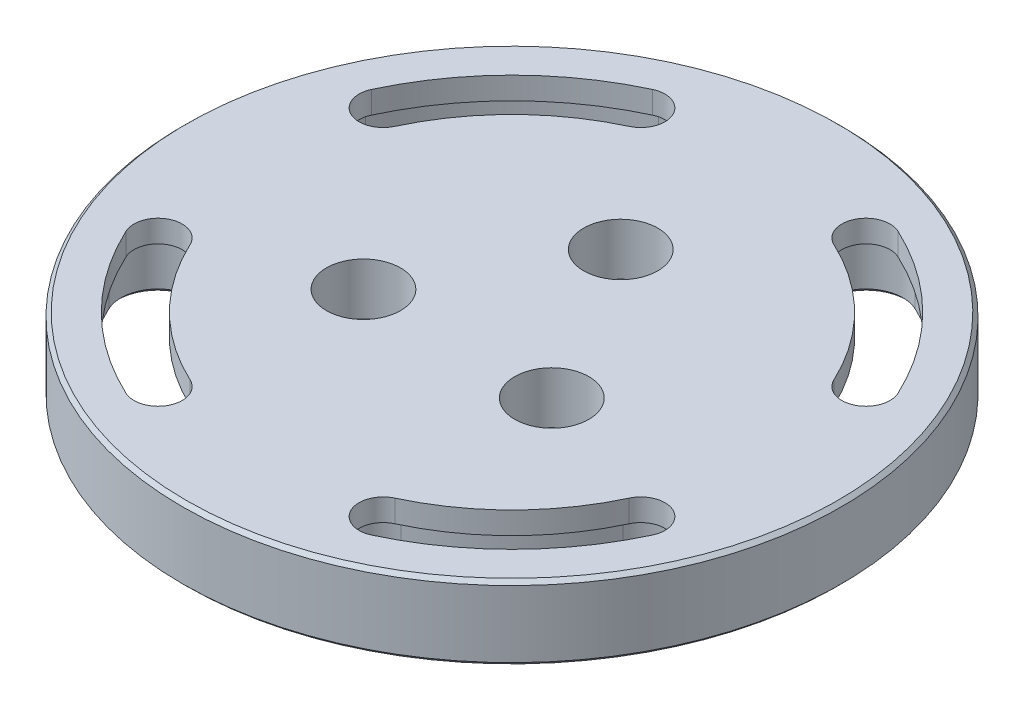
from build123d import *

# Parameters (mm, degrees)
SKETCH1_R           = 44.45
BOSS_EXTRUDE1_DEPTH = 10
BOSS_EXTRUDE2_DEPTH = 3
SKETCH3_R           = 5
CUT_EXTRUDE1_DEPTH  = 10
SKETCH4_R           = 5
SKETCH4_R_2         = 3.25
BOSS_EXTRUDE4_DEPTH = 3
CHAMFER1_SIZE       = 0.5


with BuildPart() as part:
    # Sketch1 → Boss-Extrude1 (new body)
    with BuildSketch(Plane(origin=(0, 0, 0), x_dir=(1, 0, 0), z_dir=(0, 1, 0))):
        with Locations(Location((0, 0, 0), (0, 0, 270))):
            Circle(SKETCH1_R)
        with BuildLine():
            ThreePointArc((37.087043144, 17.293972236), (28.935533906, 28.935533906), (17.293972236, 37.087043144))
            ThreePointArc((17.293972236, 37.087043144), (10.649341992, 34.668595517), (13.067789619, 28.023965273))
            ThreePointArc((13.067789619, 28.023965273), (21.864466094, 21.864466094), (28.023965273, 13.067789619))
            ThreePointArc((28.023965273, 13.067789619), (34.668595517, 10.649341992), (37.087043144, 17.293972236))
        make_face(mode=Mode.SUBTRACT)
        with BuildLine():
            ThreePointArc((17.293972236, -37.087043144), (28.935533906, -28.935533906), (37.087043144, -17.293972236))
            ThreePointArc((37.087043144, -17.293972236), (34.668595517, -10.649341992), (28.023965273, -13.067789619))
            ThreePointArc((28.023965273, -13.067789619), (21.864466094, -21.864466094), (13.067789619, -28.023965273))
            ThreePointArc((13.067789619, -28.023965273), (10.649341992, -34.668595517), (17.293972236, -37.087043144))
        make_face(mode=Mode.SUBTRACT)
        with BuildLine():
            ThreePointArc((-37.087043144, -17.293972236), (-28.935533906, -28.935533906), (-17.293972236, -37.087043144))
            ThreePointArc((-17.293972236, -37.087043144), (-10.649341992, -34.668595517), (-13.067789619, -28.023965273))
            ThreePointArc((-13.067789619, -28.023965273), (-21.864466094, -21.864466094), (-28.023965273, -13.067789619))
            ThreePointArc((-28.023965273, -13.067789619), (-34.668595517, -10.649341992), (-37.087043144, -17.293972236))
        make_face(mode=Mode.SUBTRACT)
        with BuildLine():
            ThreePointArc((-17.293972236, 37.087043144), (-28.935533906, 28.935533906), (-37.087043144, 17.293972236))
            ThreePointArc((-37.087043144, 17.293972236), (-34.668595517, 10.649341992), (-28.023965273, 13.067789619))
            ThreePointArc((-28.023965273, 13.067789619), (-21.864466094, 21.864466094), (-13.067789619, 28.023965273))
            ThreePointArc((-13.067789619, 28.023965273), (-10.649341992, 34.668595517), (-17.293972236, 37.087043144))
        make_face(mode=Mode.SUBTRACT)
    extrude(amount=BOSS_EXTRUDE1_DEPTH)

    # Sketch2 → Boss-Extrude2 (add)
    with BuildSketch(Plane(origin=(0, 10, 0), x_dir=(1, 0, 0), z_dir=(0, 1, 0))):
        with BuildLine():
            ThreePointArc((-17.293972236, 37.087043144), (-28.935533906, 28.935533906), (-37.087043144, 17.293972236))
            ThreePointArc((-37.087043144, 17.293972236), (-34.668595517, 10.649341992), (-28.023965273, 13.067789619))
            ThreePointArc((-28.023965273, 13.067789619), (-21.864466094, 21.864466094), (-13.067789619, 28.023965273))
            ThreePointArc((-13.067789619, 28.023965273), (-10.649341992, 34.668595517), (-17.293972236, 37.087043144))
        make_face()
        with BuildLine():
            ThreePointArc((-16.554390278, 35.501004516), (-12.23538062, 33.929013559), (-13.807371577, 29.610003901))
            ThreePointArc((-13.807371577, 29.610003901), (-23.101902961, 23.101902961), (-29.610003901, 13.807371577))
            ThreePointArc((-29.610003901, 13.807371577), (-33.929013559, 12.23538062), (-35.501004516, 16.554390278))
            ThreePointArc((-35.501004516, 16.554390278), (-27.698097039, 27.698097039), (-16.554390278, 35.501004516))
        make_face(mode=Mode.SUBTRACT)
        with BuildLine():
            ThreePointArc((17.293972236, 37.087043144), (10.649341992, 34.668595517), (13.067789619, 28.023965273))
            ThreePointArc((13.067789619, 28.023965273), (21.864466094, 21.864466094), (28.023965273, 13.067789619))
            ThreePointArc((28.023965273, 13.067789619), (34.668595517, 10.649341992), (37.087043144, 17.293972236))
            ThreePointArc((37.087043144, 17.293972236), (28.935533906, 28.935533906), (17.293972236, 37.087043144))
        make_face()
        with BuildLine():
            ThreePointArc((35.501004516, 16.554390278), (33.929013559, 12.23538062), (29.610003901, 13.807371577))
            ThreePointArc((29.610003901, 13.807371577), (23.101902961, 23.101902961), (13.807371577, 29.610003901))
            ThreePointArc((13.807371577, 29.610003901), (12.23538062, 33.929013559), (16.554390278, 35.501004516))
            ThreePointArc((16.554390278, 35.501004516), (27.698097039, 27.698097039), (35.501004516, 16.554390278))
        make_face(mode=Mode.SUBTRACT)
        with BuildLine():
            ThreePointArc((37.087043144, -17.293972236), (34.668595517, -10.649341992), (28.023965273, -13.067789619))
            ThreePointArc((28.023965273, -13.067789619), (21.864466094, -21.864466094), (13.067789619, -28.023965273))
            ThreePointArc((13.067789619, -28.023965273), (10.649341992, -34.668595517), (17.293972236, -37.087043144))
            ThreePointArc((17.293972236, -37.087043144), (28.935533906, -28.935533906), (37.087043144, -17.293972236))
        make_face()
        with BuildLine():
            ThreePointArc((16.554390278, -35.501004516), (12.23538062, -33.929013559), (13.807371577, -29.610003901))
            ThreePointArc((13.807371577, -29.610003901), (23.101902961, -23.101902961), (29.610003901, -13.807371577))
            ThreePointArc((29.610003901, -13.807371577), (33.929013559, -12.23538062), (35.501004516, -16.554390278))
            ThreePointArc((35.501004516, -16.554390278), (27.698097039, -27.698097039), (16.554390278, -35.501004516))
        make_face(mode=Mode.SUBTRACT)
        with BuildLine():
            ThreePointArc((-28.023965273, -13.067789619), (-34.668595517, -10.649341992), (-37.087043144, -17.293972236))
            ThreePointArc((-37.087043144, -17.293972236), (-28.935533906, -28.935533906), (-17.293972236, -37.087043144))
            ThreePointArc((-17.293972236, -37.087043144), (-10.649341992, -34.668595517), (-13.067789619, -28.023965273))
            ThreePointArc((-13.067789619, -28.023965273), (-21.864466094, -21.864466094), (-28.023965273, -13.067789619))
        make_face()
        with BuildLine():
            ThreePointArc((-35.501004516, -16.554390278), (-33.929013559, -12.23538062), (-29.610003901, -13.807371577))
            ThreePointArc((-29.610003901, -13.807371577), (-23.101902961, -23.101902961), (-13.807371577, -29.610003901))
            ThreePointArc((-13.807371577, -29.610003901), (-12.23538062, -33.929013559), (-16.554390278, -35.501004516))
            ThreePointArc((-16.554390278, -35.501004516), (-27.698097039, -27.698097039), (-35.501004516, -16.554390278))
        make_face(mode=Mode.SUBTRACT)
    extrude(amount=-BOSS_EXTRUDE2_DEPTH)

    # Sketch3 → Cut-Extrude1 (cut)
    with BuildSketch(Plane(origin=(0, 10, 0), x_dir=(1, 0, 0), z_dir=(0, 1, 0))):
        with Locations(Location((0, 14.664696837, 0), (0, 0, 270))):
            Circle(SKETCH3_R)
        with Locations(Location((-12.7, -7.332348419, 0), (0, 0, 270))):
            Circle(SKETCH3_R)
        with Locations(Location((12.7, -7.332348419, 0), (0, 0, 270))):
            Circle(SKETCH3_R)
    extrude(amount=-CUT_EXTRUDE1_DEPTH, mode=Mode.SUBTRACT)

    # Sketch4 → Boss-Extrude4 (add)
    with BuildSketch(Plane(origin=(0, 0, 0), x_dir=(1, 0, 0), z_dir=(0, 1, 0))):
        with Locations(Location((12.7, -7.332348419, 0), (0, 0, 270))):
            Circle(SKETCH4_R)
        with Locations(Location((12.7, -7.332348419, 0), (0, 0, 270))):
            Circle(SKETCH4_R_2, mode=Mode.SUBTRACT)
        with Locations(Location((-12.7, -7.332348419, 0), (0, 0, 270))):
            Circle(SKETCH4_R)
        with Locations(Location((-12.7, -7.332348419, 0), (0, 0, 270))):
            Circle(SKETCH4_R_2, mode=Mode.SUBTRACT)
        with Locations(Location((0, 14.664696837, 0), (0, 0, 270))):
            Circle(SKETCH4_R)
        with Locations(Location((0, 14.664696837, 0), (0, 0, 270))):
            Circle(SKETCH4_R_2, mode=Mode.SUBTRACT)
    extrude(amount=BOSS_EXTRUDE4_DEPTH)

    # Chamfer1
    chamfer1_edges = [part.edges().sort_by_distance(p)[0] for p in [
        (-34.668595517, 0, 10.649341992),
        (-28.935533906, 0, 28.935533906),
        (-10.649341992, 0, 34.668595517),
        (-21.864466094, 0, 21.864466094),
        (0, 0, -44.45),
        (10.649341992, 0, 34.668595517),
        (28.935533906, 0, 28.935533906),
        (34.668595517, 0, 10.649341992),
        (21.864466094, 0, 21.864466094),
        (-28.935533906, 0, -28.935533906),
        (-34.668595517, 0, -10.649341992),
        (-21.864466094, 0, -21.864466094),
        (-10.649341992, 0, -34.668595517),
        (34.668595517, 0, -10.649341992),
        (28.935533906, 0, -28.935533906),
        (10.649341992, 0, -34.668595517),
        (21.864466094, 0, -21.864466094),
        (0, 10, -44.45),
    ]]
    chamfer(chamfer1_edges, length=CHAMFER1_SIZE)


solid = part.part
